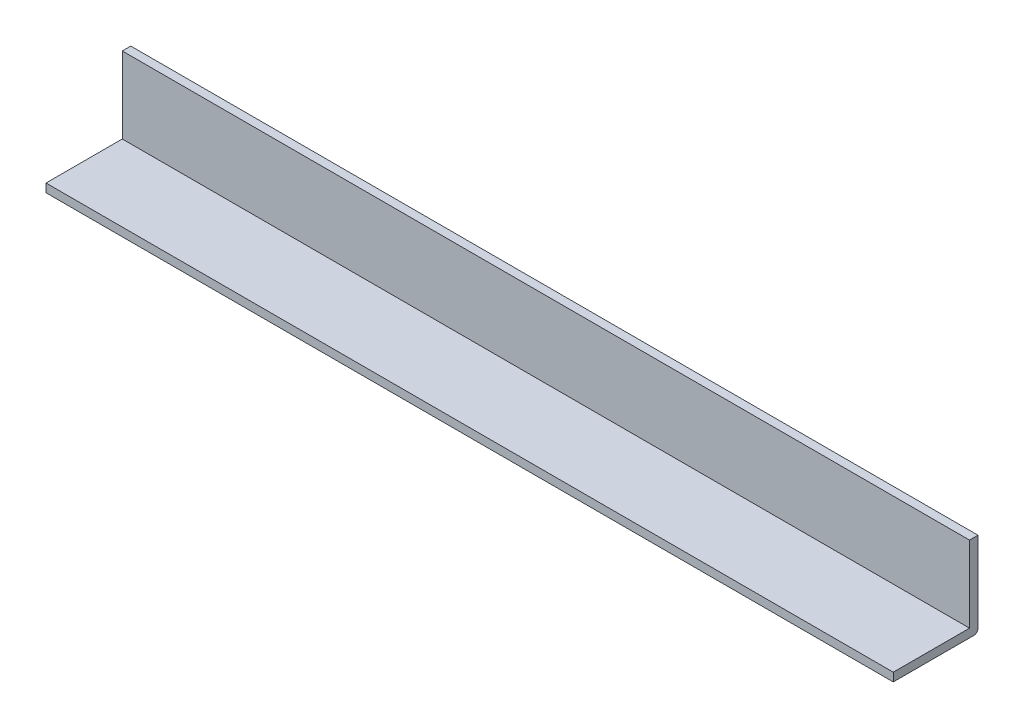
from build123d import *

# Parameters (mm, degrees)
SKETCH1_W           = 9
SKETCH1_H           = 1
SKETCH1_W_2         = 1
SKETCH1_H_2         = 9
BOSS_EXTRUDE1_DEPTH = 100


with BuildPart() as part:
    # Sketch1 → Boss-Extrude1 (new body)
    with BuildSketch(Plane(origin=(0, 0, 0), x_dir=(0, 0, -1), z_dir=(1, 0, 0))):
        with Locations((-15.137894846, 6.81112979)):
            Rectangle(SKETCH1_W, SKETCH1_H)
        with Locations((-10.137894846, 11.81112979)):
            Rectangle(SKETCH1_W_2, SKETCH1_H_2)
        with BuildLine():
            Line((-9.637894846, 7.31112979), (-10.637894846, 7.31112979))
            Line((-10.637894846, 7.31112979), (-10.637894846, 6.31112979))
            Line((-10.637894846, 6.31112979), (-10.137894846, 6.31112979))
            ThreePointArc((-10.137894846, 6.31112979), (-9.784341456, 6.4575764), (-9.637894846, 6.81112979))
            Line((-9.637894846, 6.81112979), (-9.637894846, 7.31112979))
        make_face()
    extrude(amount=BOSS_EXTRUDE1_DEPTH)


solid = part.part
